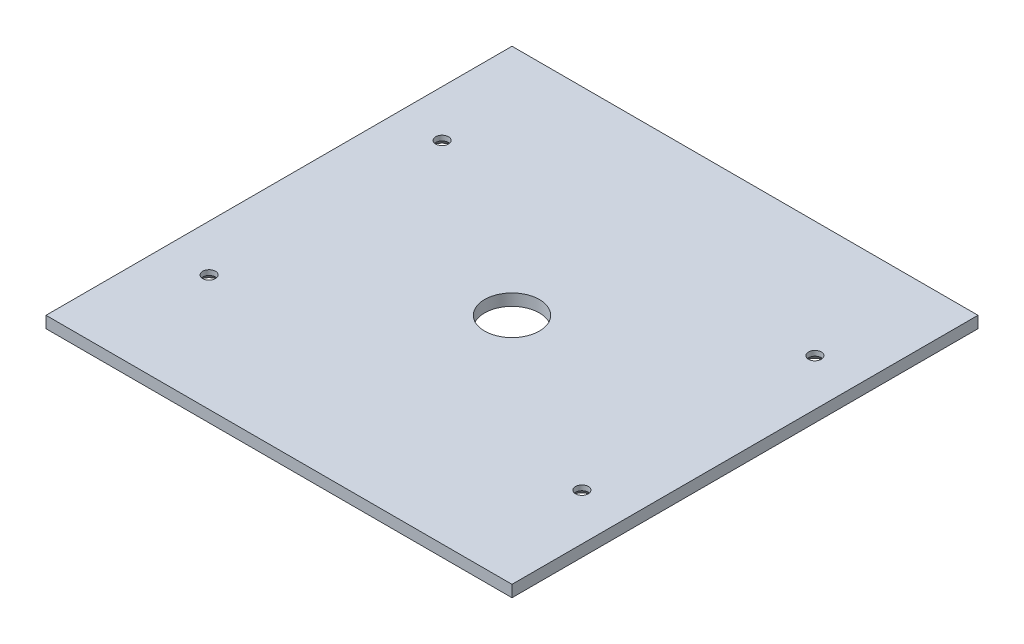
from build123d import *

# Parameters (mm, degrees)
SKETCH1_W                                           = 200
SKETCH1_H                                           = 200
BOSS_EXTRUDE1_DEPTH                                 = 5
CSK_FOR_M5_COUNTERSUNK_FLAT_HEAD_SCREW1_D           = 5.5
CSK_FOR_M5_COUNTERSUNK_FLAT_HEAD_SCREW1_DEPTH       = 10
CSK_FOR_M5_COUNTERSUNK_FLAT_HEAD_SCREW1_CSINK_D     = 11.2
CSK_FOR_M5_COUNTERSUNK_FLAT_HEAD_SCREW1_CSINK_ANGLE = 90
CSK_FOR_M5_COUNTERSUNK_FLAT_HEAD_SCREW1_TIP         = 1.652366702
SKETCH5_R                                           = 11.75
CUT_EXTRUDE1_DEPTH                                  = 10


with BuildPart() as part:
    # Sketch1 → Boss-Extrude1 (new body)
    with BuildSketch(Plane(origin=(0, 0, 0), x_dir=(1, 0, 0), z_dir=(0, 1, 0))):
        with Locations((-100, 100)):
            Rectangle(SKETCH1_W, SKETCH1_H)
    extrude(amount=BOSS_EXTRUDE1_DEPTH)

    # CSK for M5 Countersunk Flat Head Screw1
    with Locations(Plane(origin=(0, 0, 0), x_dir=(-1, 0, 0), z_dir=(0, -1, 0))):
        with Locations((180, 50), (180, 150), (20, 50), (20, 150)):
            CounterSinkHole(CSK_FOR_M5_COUNTERSUNK_FLAT_HEAD_SCREW1_D / 2, CSK_FOR_M5_COUNTERSUNK_FLAT_HEAD_SCREW1_CSINK_D / 2, depth=CSK_FOR_M5_COUNTERSUNK_FLAT_HEAD_SCREW1_DEPTH, counter_sink_angle=CSK_FOR_M5_COUNTERSUNK_FLAT_HEAD_SCREW1_CSINK_ANGLE)
            with Locations((0, 0, -(CSK_FOR_M5_COUNTERSUNK_FLAT_HEAD_SCREW1_DEPTH + CSK_FOR_M5_COUNTERSUNK_FLAT_HEAD_SCREW1_TIP / 2))):  # 118° drill point
                Cone(0, CSK_FOR_M5_COUNTERSUNK_FLAT_HEAD_SCREW1_D / 2, CSK_FOR_M5_COUNTERSUNK_FLAT_HEAD_SCREW1_TIP, mode=Mode.SUBTRACT)

    # Sketch5 → Cut-Extrude1 (cut)
    with BuildSketch(Plane.XZ):
        with Locations((-100, -100)):
            Circle(SKETCH5_R)
    extrude(amount=-CUT_EXTRUDE1_DEPTH, mode=Mode.SUBTRACT)


solid = part.part
